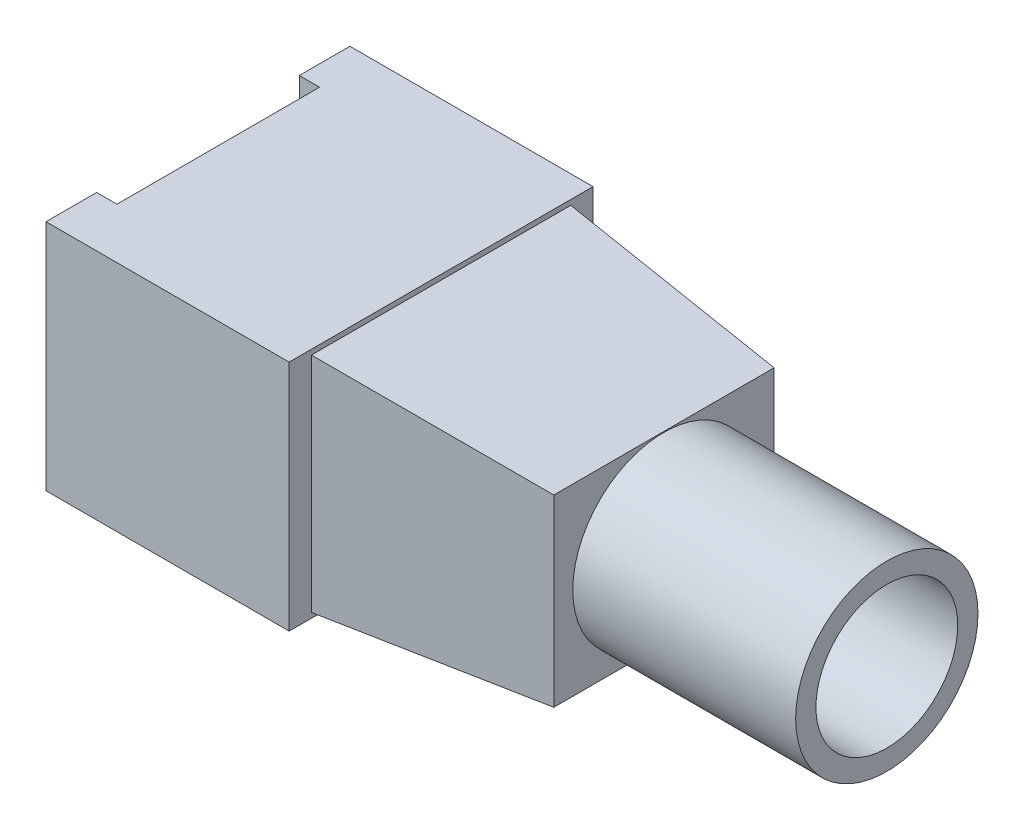
from build123d import *

# Parameters (mm, degrees)
BOSS_EXTRUDE1_DEPTH = 11.5
SKETCH4_W           = 12.8
SKETCH4_H           = 11
BOSS_EXTRUDE2_DEPTH = 11
BOSS_EXTRUDE2_TAPER = 5
SKETCH5_R           = 4.5
SKETCH5_R_2         = 3.5
BOSS_EXTRUDE3_DEPTH = 11


with BuildPart() as part:
    # Sketch2 → Boss-Extrude1 (new body)
    with BuildSketch(Plane(origin=(0, 0, 0), x_dir=(1, 0, 0), z_dir=(0, 1, 0))):
        Polygon((-6, -5), (-6, -7.5), (6, -7.5), (6, 7.5), (-6, 7.5), (-6, 5), (-5, 5), (-5, -5), align=None)
    extrude(amount=BOSS_EXTRUDE1_DEPTH)

    # Sketch4 → Boss-Extrude2 (add)
    with BuildSketch(Plane(origin=(6, 0, 0), x_dir=(0, 0, -1), z_dir=(1, 0, 0))):
        with Locations((0, 5.75)):
            Rectangle(SKETCH4_W, SKETCH4_H)
    extrude(amount=BOSS_EXTRUDE2_DEPTH, taper=BOSS_EXTRUDE2_TAPER)

    # Sketch5 → Boss-Extrude3 (add)
    with BuildSketch(Plane(origin=(17, 0, 0), x_dir=(0, 0, -1), z_dir=(1, 0, 0))):
        with Locations((0, 5.75)):
            Circle(SKETCH5_R)
        with Locations((0, 5.75)):
            Circle(SKETCH5_R_2, mode=Mode.SUBTRACT)
    extrude(amount=BOSS_EXTRUDE3_DEPTH)


solid = part.part
